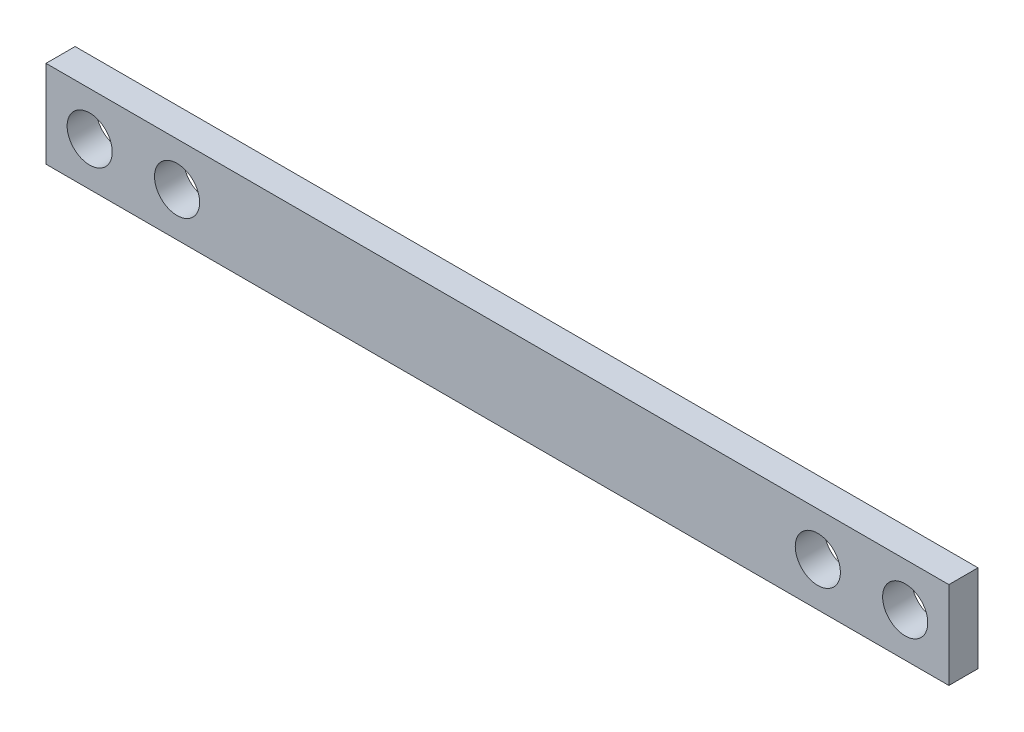
from build123d import *

# Parameters (mm, degrees)
SKETCH_1_W          = 62
SKETCH_1_H          = 6
EXTRUDE_1_DEPTH     = 2
SKETCH_2_R          = 1.55
CUT_EXTRUDE_1_DEPTH = 2


with BuildPart() as part:
    # 草图1 → 凸台-拉伸1 (new body)
    with BuildSketch(Plane.XY):
        Rectangle(SKETCH_1_W, SKETCH_1_H)
    extrude(amount=EXTRUDE_1_DEPTH)

    # 草图2 → 切除-拉伸1 (cut)
    with BuildSketch(Plane.XY.offset(2)):
        with Locations((-28, 0)):
            Circle(SKETCH_2_R)
        with Locations((-22, 0)):
            Circle(SKETCH_2_R)
        with Locations((22, 0)):
            Circle(SKETCH_2_R)
        with Locations((28, 0)):
            Circle(SKETCH_2_R)
    extrude(amount=-CUT_EXTRUDE_1_DEPTH, mode=Mode.SUBTRACT)


solid = part.part
